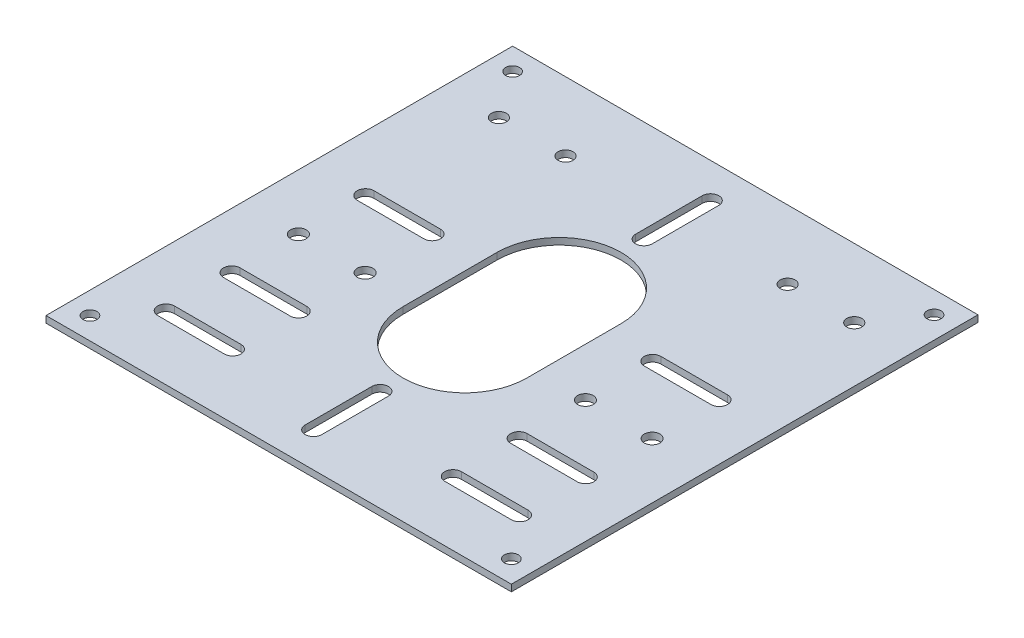
from build123d import *

# Parameters (mm, degrees)
SKETCH1_W           = 111.7
SKETCH1_H           = 112
BOSS_EXTRUDE1_DEPTH = 1.6
CUT_EXTRUDE1_DEPTH  = 1.6
SKETCH3_R           = 1.675
SKETCH3_R_2         = 1.8
SKETCH3_R_3         = 1.875
CUT_EXTRUDE2_DEPTH  = 1.6


with BuildPart() as part:
    # Sketch1 → Boss-Extrude1 (new body)
    with BuildSketch(Plane(origin=(0, 0, 0), x_dir=(1, 0, 0), z_dir=(0, 1, 0))):
        Rectangle(SKETCH1_W, SKETCH1_H)
        with BuildLine():
            Line((-14.85, -11.3), (-14.85, 11.3))
            ThreePointArc((-14.85, 11.3), (0, 26.15), (14.85, 11.3))
            Line((14.85, 11.3), (14.85, -11.3))
            ThreePointArc((14.85, -11.3), (0, -26.15), (-14.85, -11.3))
        make_face(mode=Mode.SUBTRACT)
    extrude(amount=BOSS_EXTRUDE1_DEPTH)

    # Sketch2 → Cut-Extrude1 (cut)
    with BuildSketch(Plane(origin=(0, 1.6, 0), x_dir=(1, 0, 0), z_dir=(0, 1, 0))):
        with BuildLine():
            Line((2, 47.65), (2, 31.65))
            ThreePointArc((2, 31.65), (0, 29.65), (-2, 31.65))
            Line((-2, 31.65), (-2, 47.65))
            ThreePointArc((-2, 47.65), (0, 49.65), (2, 47.65))
        make_face()
        with BuildLine():
            Line((2, -47.65), (2, -31.65))
            ThreePointArc((2, -31.65), (0, -29.65), (-2, -31.65))
            Line((-2, -31.65), (-2, -47.65))
            ThreePointArc((-2, -47.65), (0, -49.65), (2, -47.65))
        make_face()
    extrude(amount=-CUT_EXTRUDE1_DEPTH, mode=Mode.SUBTRACT)

    # Sketch3 → Cut-Extrude2 (cut)
    with BuildSketch(Plane(origin=(0, 1.6, 0), x_dir=(1, 0, 0), z_dir=(0, 1, 0))):
        with Locations((-50.575, 50.725)):
            Circle(SKETCH3_R)
        with Locations((50.575, 50.725)):
            Circle(SKETCH3_R)
        with Locations((50.575, -50.725)):
            Circle(SKETCH3_R)
        with Locations((-50.575, -50.725)):
            Circle(SKETCH3_R)
        with Locations((-42.65, 39.5)):
            Circle(SKETCH3_R_2)
        with Locations((-26.65, 39.5)):
            Circle(SKETCH3_R_2)
        with Locations((-42.45, -8.825)):
            Circle(SKETCH3_R_3)
        with Locations((-26.45, -8.825)):
            Circle(SKETCH3_R_3)
        with Locations((26.45, -8.825)):
            Circle(SKETCH3_R_3)
        with Locations((42.45, -8.825)):
            Circle(SKETCH3_R_3)
        with Locations((42.65, 39.5)):
            Circle(SKETCH3_R_2)
        with Locations((26.65, 39.5)):
            Circle(SKETCH3_R_2)
        with BuildLine():
            Line((-42.45, 9.3), (-26.45, 9.3))
            ThreePointArc((-26.45, 9.3), (-24.45, 7.3), (-26.45, 5.3))
            Line((-26.45, 5.3), (-42.45, 5.3))
            ThreePointArc((-42.45, 5.3), (-44.45, 7.3), (-42.45, 9.3))
        make_face()
        with BuildLine():
            Line((-42.45, -38.6), (-26.45, -38.6))
            ThreePointArc((-26.45, -38.6), (-24.45, -40.6), (-26.45, -42.6))
            Line((-26.45, -42.6), (-42.45, -42.6))
            ThreePointArc((-42.45, -42.6), (-44.45, -40.6), (-42.45, -38.6))
        make_face()
        with BuildLine():
            Line((-42.45, -22.8), (-26.45, -22.8))
            ThreePointArc((-26.45, -22.8), (-24.45, -24.8), (-26.45, -26.8))
            Line((-26.45, -26.8), (-42.45, -26.8))
            ThreePointArc((-42.45, -26.8), (-44.45, -24.8), (-42.45, -22.8))
        make_face()
        with BuildLine():
            Line((42.45, -38.6), (26.45, -38.6))
            ThreePointArc((26.45, -38.6), (24.45, -40.6), (26.45, -42.6))
            Line((26.45, -42.6), (42.45, -42.6))
            ThreePointArc((42.45, -42.6), (44.45, -40.6), (42.45, -38.6))
        make_face()
        with BuildLine():
            Line((42.45, -22.8), (26.45, -22.8))
            ThreePointArc((26.45, -22.8), (24.45, -24.8), (26.45, -26.8))
            Line((26.45, -26.8), (42.45, -26.8))
            ThreePointArc((42.45, -26.8), (44.45, -24.8), (42.45, -22.8))
        make_face()
        with BuildLine():
            Line((42.45, 9.3), (26.45, 9.3))
            ThreePointArc((26.45, 9.3), (24.45, 7.3), (26.45, 5.3))
            Line((26.45, 5.3), (42.45, 5.3))
            ThreePointArc((42.45, 5.3), (44.45, 7.3), (42.45, 9.3))
        make_face()
    extrude(amount=-CUT_EXTRUDE2_DEPTH, mode=Mode.SUBTRACT)


solid = part.part
